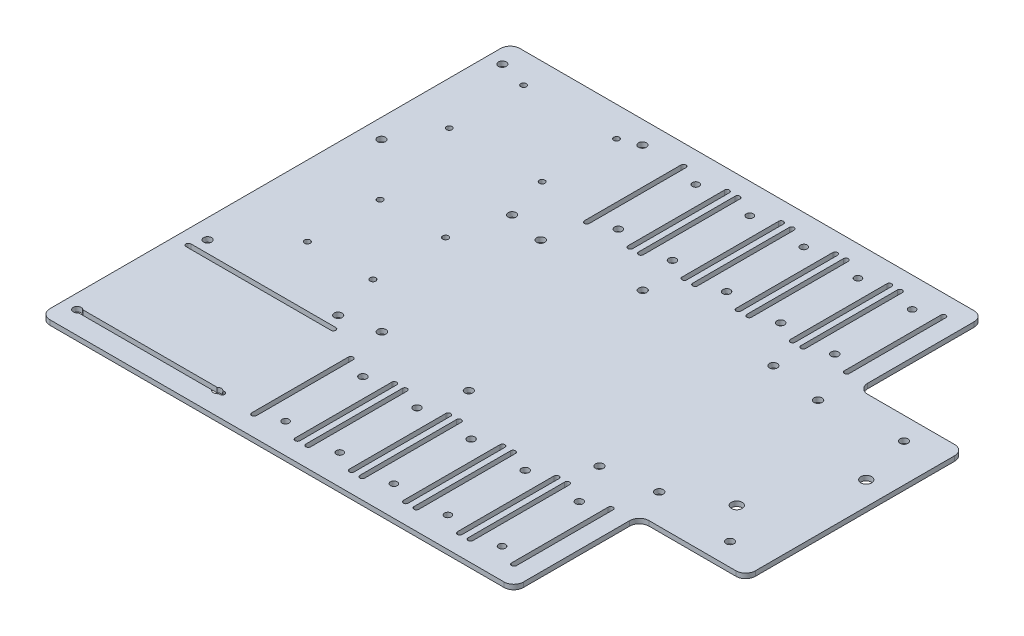
from build123d import *

# Parameters (mm, degrees)
SKETCH1_W           = 522.213812682
SKETCH1_H           = 731.32295859
BOSS_EXTRUDE1_DEPTH = 3.175
SKETCH3_W           = 1.5875
SKETCH3_H           = 63.5
CUT_EXTRUDE2_DEPTH  = 4.175
SKETCH5_R           = 2.44336951
SKETCH5_R_2         = 2.2479
CUT_EXTRUDE3_DEPTH  = 4.175
CUT_EXTRUDE6_DEPTH  = 4.175
CUT_EXTRUDE7_DEPTH  = 4.175
SKETCH10_W          = 95.25
SKETCH10_H          = 1.5875
CUT_EXTRUDE9_DEPTH  = 4.175
SKETCH11_W          = 522.213812682
SKETCH11_H          = 186.464479295
CUT_EXTRUDE10_DEPTH = 4.175
SKETCH12_W          = 244.054011645
SKETCH12_H          = 358.394
BOSS_EXTRUDE3_DEPTH = 3.175
SKETCH14_W          = 61.487666114
SKETCH14_H          = 358.394
SKETCH14_W_2        = 155.120959935
CUT_EXTRUDE12_DEPTH = 4.175
SKETCH15_W          = 381
SKETCH15_H          = 24.776559824
SKETCH15_W_2        = 31.995256138
SKETCH15_H_2        = 154.420440176
CUT_EXTRUDE13_DEPTH = 4.175
SKETCH16_R          = 2.6
CUT_EXTRUDE14_DEPTH = 4.175
CUT_EXTRUDE15_DEPTH = 4.175
SKETCH18_W          = 69.85
SKETCH18_H          = 82.55
CUT_EXTRUDE16_DEPTH = 4.175
FILLET2_R           = 6.35


with BuildPart() as part:
    # Sketch1 → Boss-Extrude1 (new body)
    with BuildSketch(Plane(origin=(0, 0, 0), x_dir=(1, 0, 0), z_dir=(0, 1, 0))):
        Rectangle(SKETCH1_W, SKETCH1_H)
    extrude(amount=BOSS_EXTRUDE1_DEPTH)

    # Sketch3 → Cut-Extrude2 (cut, through all)
    with BuildSketch(Plane(origin=(0, 3.175, 0), x_dir=(1, 0, 0), z_dir=(0, 1, 0))):
        with BuildLine():
            Line((-84.61375, -141.097), (-86.20125, -141.097))
            Line((-86.20125, -141.097), (-86.20125, -77.597))
            Line((-86.20125, -77.597), (-84.61375, -77.597))
            ThreePointArc((-84.61375, -77.597), (-86.20125, -76.0095), (-87.78875, -77.597))
            Line((-87.78875, -77.597), (-87.78875, -141.097))
            ThreePointArc((-87.78875, -141.097), (-86.20125, -142.6845), (-84.61375, -141.097))
        make_face()
        with Locations((-85.4075, -109.347)):
            Rectangle(SKETCH3_W, SKETCH3_H)
        with Locations((-58.42, -109.347)):
            Rectangle(SKETCH3_W, SKETCH3_H)
        with BuildLine():
            Line((-57.62625, -141.097), (-59.21375, -141.097))
            ThreePointArc((-59.21375, -141.097), (-57.62625, -142.6845), (-56.03875, -141.097))
            Line((-56.03875, -141.097), (-56.03875, -77.597))
            ThreePointArc((-56.03875, -77.597), (-57.62625, -76.0095), (-59.21375, -77.597))
            Line((-59.21375, -77.597), (-57.62625, -77.597))
            Line((-57.62625, -77.597), (-57.62625, -141.097))
        make_face()
        with BuildLine():
            Line((-49.05375, -141.097), (-49.05375, -77.597))
            ThreePointArc((-49.05375, -77.597), (-50.64125, -76.0095), (-52.22875, -77.597))
            Line((-52.22875, -77.597), (-52.22875, -141.097))
            ThreePointArc((-52.22875, -141.097), (-50.64125, -142.6845), (-49.05375, -141.097))
        make_face()
        with BuildLine():
            Line((-20.47875, -141.097), (-20.47875, -77.597))
            ThreePointArc((-20.47875, -77.597), (-22.06625, -76.0095), (-23.65375, -77.597))
            Line((-23.65375, -77.597), (-23.65375, -141.097))
            ThreePointArc((-23.65375, -141.097), (-22.06625, -142.6845), (-20.47875, -141.097))
        make_face()
        with BuildLine():
            Line((-13.49375, -141.097), (-13.49375, -77.597))
            ThreePointArc((-13.49375, -77.597), (-15.08125, -76.0095), (-16.66875, -77.597))
            Line((-16.66875, -77.597), (-16.66875, -141.097))
            ThreePointArc((-16.66875, -141.097), (-15.08125, -142.6845), (-13.49375, -141.097))
        make_face()
        with BuildLine():
            Line((15.08125, -141.097), (15.08125, -77.597))
            ThreePointArc((15.08125, -77.597), (13.49375, -76.0095), (11.90625, -77.597))
            Line((11.90625, -77.597), (11.90625, -141.097))
            ThreePointArc((11.90625, -141.097), (13.49375, -142.6845), (15.08125, -141.097))
        make_face()
        with BuildLine():
            Line((22.06625, -141.097), (22.06625, -77.597))
            ThreePointArc((22.06625, -77.597), (20.47875, -76.0095), (18.89125, -77.597))
            Line((18.89125, -77.597), (18.89125, -141.097))
            ThreePointArc((18.89125, -141.097), (20.47875, -142.6845), (22.06625, -141.097))
        make_face()
        with BuildLine():
            Line((50.64125, -141.097), (50.64125, -77.597))
            ThreePointArc((50.64125, -77.597), (49.05375, -76.0095), (47.46625, -77.597))
            Line((47.46625, -77.597), (47.46625, -141.097))
            ThreePointArc((47.46625, -141.097), (49.05375, -142.6845), (50.64125, -141.097))
        make_face()
        with BuildLine():
            Line((57.62625, -141.097), (57.62625, -77.597))
            ThreePointArc((57.62625, -77.597), (56.03875, -76.0095), (54.45125, -77.597))
            Line((54.45125, -77.597), (54.45125, -141.097))
            ThreePointArc((54.45125, -141.097), (56.03875, -142.6845), (57.62625, -141.097))
        make_face()
        with BuildLine():
            Line((86.20125, -141.097), (86.20125, -77.597))
            ThreePointArc((86.20125, -77.597), (84.61375, -76.0095), (83.02625, -77.597))
            Line((83.02625, -77.597), (83.02625, -141.097))
            ThreePointArc((83.02625, -141.097), (84.61375, -142.6845), (86.20125, -141.097))
        make_face()
        with BuildLine():
            ThreePointArc((-88.4682, -52.197), (-89.249346215, -50.311146215), (-91.1352, -49.53))
            Line((-91.1352, -49.53), (-91.1352, -52.197))
            Line((-91.1352, -52.197), (-88.4682, -52.197))
        make_face()
        with BuildLine():
            Line((-91.1352, -52.197), (-91.1352, -49.53))
            ThreePointArc((-91.1352, -49.53), (-93.021053785, -54.082853785), (-88.4682, -52.197))
            Line((-88.4682, -52.197), (-91.1352, -52.197))
        make_face()
        with BuildLine():
            ThreePointArc((-88.4682, -52.197), (-89.249346215, -50.311146215), (-91.1352, -49.53))
            Line((-91.1352, -49.53), (-91.1352, -52.197))
            Line((-91.1352, -52.197), (-88.4682, -52.197))
        make_face()
        with BuildLine():
            Line((-91.1352, -52.197), (-91.1352, -49.53))
            ThreePointArc((-91.1352, -49.53), (-93.021053785, -54.082853785), (-88.4682, -52.197))
            Line((-88.4682, -52.197), (-91.1352, -52.197))
        make_face()
        with BuildLine():
            ThreePointArc((-91.1352, 49.53), (-89.249346215, 50.311146215), (-88.4682, 52.197))
            Line((-88.4682, 52.197), (-91.1352, 52.197))
            Line((-91.1352, 52.197), (-91.1352, 49.53))
        make_face()
        with BuildLine():
            Line((-91.1352, 52.197), (-88.4682, 52.197))
            ThreePointArc((-88.4682, 52.197), (-93.021053785, 54.082853785), (-91.1352, 49.53))
            Line((-91.1352, 49.53), (-91.1352, 52.197))
        make_face()
        with BuildLine():
            ThreePointArc((-91.1352, 49.53), (-89.249346215, 50.311146215), (-88.4682, 52.197))
            Line((-88.4682, 52.197), (-91.1352, 52.197))
            Line((-91.1352, 52.197), (-91.1352, 49.53))
        make_face()
        with BuildLine():
            Line((-91.1352, 52.197), (-88.4682, 52.197))
            ThreePointArc((-88.4682, 52.197), (-93.021053785, 54.082853785), (-91.1352, 49.53))
            Line((-91.1352, 49.53), (-91.1352, 52.197))
        make_face()
        with BuildLine():
            ThreePointArc((93.8022, 52.197), (91.1352, 54.864), (88.4682, 52.197))
            Line((88.4682, 52.197), (91.1352, 52.197))
            Line((91.1352, 52.197), (91.1352, 49.53))
            ThreePointArc((91.1352, 49.53), (93.021053785, 50.311146215), (93.8022, 52.197))
        make_face()
        with BuildLine():
            Line((91.1352, 52.197), (88.4682, 52.197))
            ThreePointArc((88.4682, 52.197), (89.249346215, 50.311146215), (91.1352, 49.53))
            Line((91.1352, 49.53), (91.1352, 52.197))
        make_face()
        with BuildLine():
            ThreePointArc((93.8022, 52.197), (91.1352, 54.864), (88.4682, 52.197))
            Line((88.4682, 52.197), (91.1352, 52.197))
            Line((91.1352, 52.197), (91.1352, 49.53))
            ThreePointArc((91.1352, 49.53), (93.021053785, 50.311146215), (93.8022, 52.197))
        make_face()
        with BuildLine():
            Line((91.1352, 52.197), (88.4682, 52.197))
            ThreePointArc((88.4682, 52.197), (89.249346215, 50.311146215), (91.1352, 49.53))
            Line((91.1352, 49.53), (91.1352, 52.197))
        make_face()
        with BuildLine():
            ThreePointArc((93.8022, -52.197), (93.021053785, -50.311146215), (91.1352, -49.53))
            Line((91.1352, -49.53), (91.1352, -52.197))
            Line((91.1352, -52.197), (88.4682, -52.197))
            ThreePointArc((88.4682, -52.197), (91.1352, -54.864), (93.8022, -52.197))
        make_face()
        with BuildLine():
            Line((91.1352, -52.197), (91.1352, -49.53))
            ThreePointArc((91.1352, -49.53), (89.249346215, -50.311146215), (88.4682, -52.197))
            Line((88.4682, -52.197), (91.1352, -52.197))
        make_face()
        with BuildLine():
            ThreePointArc((93.8022, -52.197), (93.021053785, -50.311146215), (91.1352, -49.53))
            Line((91.1352, -49.53), (91.1352, -52.197))
            Line((91.1352, -52.197), (88.4682, -52.197))
            ThreePointArc((88.4682, -52.197), (91.1352, -54.864), (93.8022, -52.197))
        make_face()
        with BuildLine():
            Line((91.1352, -52.197), (91.1352, -49.53))
            ThreePointArc((91.1352, -49.53), (89.249346215, -50.311146215), (88.4682, -52.197))
            Line((88.4682, -52.197), (91.1352, -52.197))
        make_face()
        with BuildLine():
            ThreePointArc((86.20125, 77.597), (84.61375, 76.0095), (83.02625, 77.597))
            Line((83.02625, 77.597), (83.02625, 141.097))
            ThreePointArc((83.02625, 141.097), (84.61375, 142.6845), (86.20125, 141.097))
            Line((86.20125, 141.097), (86.20125, 77.597))
        make_face()
        with BuildLine():
            ThreePointArc((50.64125, 77.597), (49.05375, 76.0095), (47.46625, 77.597))
            Line((47.46625, 77.597), (47.46625, 141.097))
            ThreePointArc((47.46625, 141.097), (49.05375, 142.6845), (50.64125, 141.097))
            Line((50.64125, 141.097), (50.64125, 77.597))
        make_face()
        with BuildLine():
            ThreePointArc((57.62625, 77.597), (56.03875, 76.0095), (54.45125, 77.597))
            Line((54.45125, 77.597), (54.45125, 141.097))
            ThreePointArc((54.45125, 141.097), (56.03875, 142.6845), (57.62625, 141.097))
            Line((57.62625, 141.097), (57.62625, 77.597))
        make_face()
        with BuildLine():
            ThreePointArc((15.08125, 77.597), (13.49375, 76.0095), (11.90625, 77.597))
            Line((11.90625, 77.597), (11.90625, 141.097))
            ThreePointArc((11.90625, 141.097), (13.49375, 142.6845), (15.08125, 141.097))
            Line((15.08125, 141.097), (15.08125, 77.597))
        make_face()
        with BuildLine():
            ThreePointArc((22.06625, 77.597), (20.47875, 76.0095), (18.89125, 77.597))
            Line((18.89125, 77.597), (18.89125, 141.097))
            ThreePointArc((18.89125, 141.097), (20.47875, 142.6845), (22.06625, 141.097))
            Line((22.06625, 141.097), (22.06625, 77.597))
        make_face()
        with BuildLine():
            ThreePointArc((-20.47875, 77.597), (-22.06625, 76.0095), (-23.65375, 77.597))
            Line((-23.65375, 77.597), (-23.65375, 141.097))
            ThreePointArc((-23.65375, 141.097), (-22.06625, 142.6845), (-20.47875, 141.097))
            Line((-20.47875, 141.097), (-20.47875, 77.597))
        make_face()
        with BuildLine():
            ThreePointArc((-13.49375, 77.597), (-15.08125, 76.0095), (-16.66875, 77.597))
            Line((-16.66875, 77.597), (-16.66875, 141.097))
            ThreePointArc((-16.66875, 141.097), (-15.08125, 142.6845), (-13.49375, 141.097))
            Line((-13.49375, 141.097), (-13.49375, 77.597))
        make_face()
        with BuildLine():
            ThreePointArc((-56.03875, 77.597), (-57.62625, 76.0095), (-59.21375, 77.597))
            Line((-59.21375, 77.597), (-59.21375, 141.097))
            ThreePointArc((-59.21375, 141.097), (-57.62625, 142.6845), (-56.03875, 141.097))
            Line((-56.03875, 141.097), (-56.03875, 77.597))
        make_face()
        with BuildLine():
            ThreePointArc((-49.05375, 77.597), (-50.64125, 76.0095), (-52.22875, 77.597))
            Line((-52.22875, 77.597), (-52.22875, 141.097))
            ThreePointArc((-52.22875, 141.097), (-50.64125, 142.6845), (-49.05375, 141.097))
            Line((-49.05375, 141.097), (-49.05375, 77.597))
        make_face()
        with BuildLine():
            ThreePointArc((-84.61375, 77.597), (-86.20125, 76.0095), (-87.78875, 77.597))
            Line((-87.78875, 77.597), (-87.78875, 141.097))
            ThreePointArc((-87.78875, 141.097), (-86.20125, 142.6845), (-84.61375, 141.097))
            Line((-84.61375, 141.097), (-84.61375, 77.597))
        make_face()
    extrude(amount=-CUT_EXTRUDE2_DEPTH, mode=Mode.SUBTRACT)

    # Sketch5 → Cut-Extrude3 (cut, through all)
    with BuildSketch(Plane(origin=(0, 3.175, 0), x_dir=(1, 0, 0), z_dir=(0, 1, 0))):
        with Locations((-71.8467829, -83.947)):
            Circle(SKETCH5_R)
        with Locations((-71.8467829, -134.747)):
            Circle(SKETCH5_R_2)
        with Locations((-36.2867829, -134.747)):
            Circle(SKETCH5_R_2)
        with Locations((-36.2867829, -83.947)):
            Circle(SKETCH5_R)
        with Locations((70.3932171, -83.947)):
            Circle(SKETCH5_R)
        with Locations((70.3932171, -134.747)):
            Circle(SKETCH5_R_2)
        with Locations((34.8332171, -83.947)):
            Circle(SKETCH5_R)
        with Locations((34.8332171, -134.747)):
            Circle(SKETCH5_R_2)
        with Locations((-0.7267829, -134.747)):
            Circle(SKETCH5_R_2)
        with Locations((-0.7267829, -83.947)):
            Circle(SKETCH5_R)
        with Locations((70.3932171, 83.947)):
            Circle(SKETCH5_R)
        with Locations((34.8332171, 83.947)):
            Circle(SKETCH5_R)
        with Locations((34.8332171, 134.747)):
            Circle(SKETCH5_R_2)
        with Locations((70.3932171, 134.747)):
            Circle(SKETCH5_R_2)
        with Locations((-0.7267829, 134.747)):
            Circle(SKETCH5_R_2)
        with Locations((-0.7267829, 83.947)):
            Circle(SKETCH5_R)
        with Locations((-36.2867829, 83.947)):
            Circle(SKETCH5_R)
        with Locations((-36.2867829, 134.747)):
            Circle(SKETCH5_R_2)
        with Locations((-71.8467829, 134.747)):
            Circle(SKETCH5_R_2)
        with Locations((-71.8467829, 83.947)):
            Circle(SKETCH5_R)
    extrude(amount=-CUT_EXTRUDE3_DEPTH, mode=Mode.SUBTRACT)

    # Sketch8 → Cut-Extrude6 (cut, through all)
    with BuildSketch(Plane(origin=(0, 3.175, 0), x_dir=(1, 0, 0), z_dir=(0, 1, 0))):
        with BuildLine():
            ThreePointArc((148.68525, 22.761479295), (149.726778286, 20.247007581), (152.24125, 19.205479295))
            Line((152.24125, 19.205479295), (152.24125, 22.761479295))
            Line((152.24125, 22.761479295), (148.68525, 22.761479295))
        make_face()
        with BuildLine():
            Line((152.24125, 22.761479295), (152.24125, 19.205479295))
            ThreePointArc((152.24125, 19.205479295), (154.755721714, 20.247007581), (155.79725, 22.761479295))
            ThreePointArc((155.79725, 22.761479295), (152.24125, 26.317479295), (148.68525, 22.761479295))
            Line((148.68525, 22.761479295), (152.24125, 22.761479295))
        make_face()
        with BuildLine():
            ThreePointArc((148.68525, 22.761479295), (149.726778286, 20.247007581), (152.24125, 19.205479295))
            Line((152.24125, 19.205479295), (152.24125, 22.761479295))
            Line((152.24125, 22.761479295), (148.68525, 22.761479295))
        make_face()
        with BuildLine():
            Line((152.24125, 22.761479295), (152.24125, 19.205479295))
            ThreePointArc((152.24125, 19.205479295), (154.755721714, 20.247007581), (155.79725, 22.761479295))
            ThreePointArc((155.79725, 22.761479295), (152.24125, 26.317479295), (148.68525, 22.761479295))
            Line((148.68525, 22.761479295), (152.24125, 22.761479295))
        make_face()
        with BuildLine():
            ThreePointArc((124.30125, -30.832520705), (121.786778286, -36.902992419), (127.85725, -34.388520705))
            Line((127.85725, -34.388520705), (124.30125, -34.388520705))
            Line((124.30125, -34.388520705), (124.30125, -30.832520705))
        make_face()
        with BuildLine():
            Line((124.30125, -34.388520705), (127.85725, -34.388520705))
            ThreePointArc((127.85725, -34.388520705), (126.815721714, -31.874048991), (124.30125, -30.832520705))
            Line((124.30125, -30.832520705), (124.30125, -34.388520705))
        make_face()
        with BuildLine():
            ThreePointArc((124.30125, -30.832520705), (121.786778286, -36.902992419), (127.85725, -34.388520705))
            Line((127.85725, -34.388520705), (124.30125, -34.388520705))
            Line((124.30125, -34.388520705), (124.30125, -30.832520705))
        make_face()
        with BuildLine():
            Line((124.30125, -34.388520705), (127.85725, -34.388520705))
            ThreePointArc((127.85725, -34.388520705), (126.815721714, -31.874048991), (124.30125, -30.832520705))
            Line((124.30125, -30.832520705), (124.30125, -34.388520705))
        make_face()
    extrude(amount=-CUT_EXTRUDE6_DEPTH, mode=Mode.SUBTRACT)

    # Sketch9 → Cut-Extrude7 (cut, through all)
    with BuildSketch(Plane(origin=(0, 3.175, 0), x_dir=(1, 0, 0), z_dir=(0, 1, 0))):
        with BuildLine():
            Line((-166.923706341, -23.4442), (-166.923706341, -25.3492))
            Line((-166.923706341, -25.3492), (-165.018706341, -25.3492))
            ThreePointArc((-165.018706341, -25.3492), (-165.576667923, -24.002161582), (-166.923706341, -23.4442))
        make_face()
        with BuildLine():
            Line((-165.018706341, -25.3492), (-166.923706341, -25.3492))
            Line((-166.923706341, -25.3492), (-166.923706341, -23.4442))
            ThreePointArc((-166.923706341, -23.4442), (-168.270744759, -26.696238418), (-165.018706341, -25.3492))
        make_face()
        with BuildLine():
            Line((-166.923706341, -23.4442), (-166.923706341, -25.3492))
            Line((-166.923706341, -25.3492), (-165.018706341, -25.3492))
            ThreePointArc((-165.018706341, -25.3492), (-165.576667923, -24.002161582), (-166.923706341, -23.4442))
        make_face()
        with BuildLine():
            Line((-165.018706341, -25.3492), (-166.923706341, -25.3492))
            Line((-166.923706341, -25.3492), (-166.923706341, -23.4442))
            ThreePointArc((-166.923706341, -23.4442), (-168.270744759, -26.696238418), (-165.018706341, -25.3492))
        make_face()
        with BuildLine():
            ThreePointArc((-165.018706341, 22.4028), (-168.270744759, 23.749838418), (-166.923706341, 20.4978))
            Line((-166.923706341, 20.4978), (-166.923706341, 22.4028))
            Line((-166.923706341, 22.4028), (-165.018706341, 22.4028))
        make_face()
        with BuildLine():
            Line((-166.923706341, 22.4028), (-166.923706341, 20.4978))
            ThreePointArc((-166.923706341, 20.4978), (-165.576667923, 21.055761582), (-165.018706341, 22.4028))
            Line((-165.018706341, 22.4028), (-166.923706341, 22.4028))
        make_face()
        with BuildLine():
            ThreePointArc((-165.018706341, 22.4028), (-168.270744759, 23.749838418), (-166.923706341, 20.4978))
            Line((-166.923706341, 20.4978), (-166.923706341, 22.4028))
            Line((-166.923706341, 22.4028), (-165.018706341, 22.4028))
        make_face()
        with BuildLine():
            Line((-166.923706341, 22.4028), (-166.923706341, 20.4978))
            ThreePointArc((-166.923706341, 20.4978), (-165.576667923, 21.055761582), (-165.018706341, 22.4028))
            Line((-165.018706341, 22.4028), (-166.923706341, 22.4028))
        make_face()
        with BuildLine():
            ThreePointArc((-125.775706341, 22.4028), (-125.217744759, 21.055761582), (-123.870706341, 20.4978))
            Line((-123.870706341, 20.4978), (-123.870706341, 22.4028))
            Line((-123.870706341, 22.4028), (-125.775706341, 22.4028))
        make_face()
        with BuildLine():
            Line((-123.870706341, 22.4028), (-123.870706341, 20.4978))
            ThreePointArc((-123.870706341, 20.4978), (-122.523667923, 21.055761582), (-121.965706341, 22.4028))
            ThreePointArc((-121.965706341, 22.4028), (-123.870706341, 24.3078), (-125.775706341, 22.4028))
            Line((-125.775706341, 22.4028), (-123.870706341, 22.4028))
        make_face()
        with BuildLine():
            ThreePointArc((-125.775706341, 22.4028), (-125.217744759, 21.055761582), (-123.870706341, 20.4978))
            Line((-123.870706341, 20.4978), (-123.870706341, 22.4028))
            Line((-123.870706341, 22.4028), (-125.775706341, 22.4028))
        make_face()
        with BuildLine():
            Line((-123.870706341, 22.4028), (-123.870706341, 20.4978))
            ThreePointArc((-123.870706341, 20.4978), (-122.523667923, 21.055761582), (-121.965706341, 22.4028))
            ThreePointArc((-121.965706341, 22.4028), (-123.870706341, 24.3078), (-125.775706341, 22.4028))
            Line((-125.775706341, 22.4028), (-123.870706341, 22.4028))
        make_face()
        with BuildLine():
            ThreePointArc((-123.870706341, -23.4442), (-125.217744759, -24.002161582), (-125.775706341, -25.3492))
            Line((-125.775706341, -25.3492), (-123.870706341, -25.3492))
            Line((-123.870706341, -25.3492), (-123.870706341, -23.4442))
        make_face()
        with BuildLine():
            Line((-123.870706341, -25.3492), (-125.775706341, -25.3492))
            ThreePointArc((-125.775706341, -25.3492), (-123.870706341, -27.2542), (-121.965706341, -25.3492))
            ThreePointArc((-121.965706341, -25.3492), (-122.523667923, -24.002161582), (-123.870706341, -23.4442))
            Line((-123.870706341, -23.4442), (-123.870706341, -25.3492))
        make_face()
        with BuildLine():
            ThreePointArc((-123.870706341, -23.4442), (-125.217744759, -24.002161582), (-125.775706341, -25.3492))
            Line((-125.775706341, -25.3492), (-123.870706341, -25.3492))
            Line((-123.870706341, -25.3492), (-123.870706341, -23.4442))
        make_face()
        with BuildLine():
            Line((-123.870706341, -25.3492), (-125.775706341, -25.3492))
            ThreePointArc((-125.775706341, -25.3492), (-123.870706341, -27.2542), (-121.965706341, -25.3492))
            ThreePointArc((-121.965706341, -25.3492), (-122.523667923, -24.002161582), (-123.870706341, -23.4442))
            Line((-123.870706341, -23.4442), (-123.870706341, -25.3492))
        make_face()
        with BuildLine():
            ThreePointArc((-123.870706341, 87.74176), (-125.171047428, 87.203141086), (-125.709666341, 85.9028))
            Line((-125.709666341, 85.9028), (-123.870706341, 85.9028))
            Line((-123.870706341, 85.9028), (-123.870706341, 87.74176))
        make_face()
        with BuildLine():
            Line((-123.870706341, 85.9028), (-125.709666341, 85.9028))
            ThreePointArc((-125.709666341, 85.9028), (-123.870706341, 84.06384), (-122.031746341, 85.9028))
            ThreePointArc((-122.031746341, 85.9028), (-122.570365255, 87.203141086), (-123.870706341, 87.74176))
            Line((-123.870706341, 87.74176), (-123.870706341, 85.9028))
        make_face()
        with BuildLine():
            ThreePointArc((-123.870706341, 87.74176), (-125.171047428, 87.203141086), (-125.709666341, 85.9028))
            Line((-125.709666341, 85.9028), (-123.870706341, 85.9028))
            Line((-123.870706341, 85.9028), (-123.870706341, 87.74176))
        make_face()
        with BuildLine():
            Line((-123.870706341, 85.9028), (-125.709666341, 85.9028))
            ThreePointArc((-125.709666341, 85.9028), (-123.870706341, 84.06384), (-122.031746341, 85.9028))
            ThreePointArc((-122.031746341, 85.9028), (-122.570365255, 87.203141086), (-123.870706341, 87.74176))
            Line((-123.870706341, 87.74176), (-123.870706341, 85.9028))
        make_face()
        with BuildLine():
            ThreePointArc((-125.709666341, 134.747), (-125.171047428, 133.446658914), (-123.870706341, 132.90804))
            Line((-123.870706341, 132.90804), (-123.870706341, 134.747))
            Line((-123.870706341, 134.747), (-125.709666341, 134.747))
        make_face()
        with BuildLine():
            Line((-123.870706341, 134.747), (-123.870706341, 132.90804))
            ThreePointArc((-123.870706341, 132.90804), (-122.570365255, 133.446658914), (-122.031746341, 134.747))
            ThreePointArc((-122.031746341, 134.747), (-123.870706341, 136.58596), (-125.709666341, 134.747))
            Line((-125.709666341, 134.747), (-123.870706341, 134.747))
        make_face()
        with BuildLine():
            ThreePointArc((-125.709666341, 134.747), (-125.171047428, 133.446658914), (-123.870706341, 132.90804))
            Line((-123.870706341, 132.90804), (-123.870706341, 134.747))
            Line((-123.870706341, 134.747), (-125.709666341, 134.747))
        make_face()
        with BuildLine():
            Line((-123.870706341, 134.747), (-123.870706341, 132.90804))
            ThreePointArc((-123.870706341, 132.90804), (-122.570365255, 133.446658914), (-122.031746341, 134.747))
            ThreePointArc((-122.031746341, 134.747), (-123.870706341, 136.58596), (-125.709666341, 134.747))
            Line((-125.709666341, 134.747), (-123.870706341, 134.747))
        make_face()
        with BuildLine():
            ThreePointArc((-183.067946341, 134.747), (-186.207247428, 136.047341086), (-184.906906341, 132.90804))
            Line((-184.906906341, 132.90804), (-184.906906341, 134.747))
            Line((-184.906906341, 134.747), (-183.067946341, 134.747))
        make_face()
        with BuildLine():
            Line((-184.906906341, 134.747), (-184.906906341, 132.90804))
            ThreePointArc((-184.906906341, 132.90804), (-183.606565255, 133.446658914), (-183.067946341, 134.747))
            Line((-183.067946341, 134.747), (-184.906906341, 134.747))
        make_face()
        with BuildLine():
            ThreePointArc((-183.067946341, 134.747), (-186.207247428, 136.047341086), (-184.906906341, 132.90804))
            Line((-184.906906341, 132.90804), (-184.906906341, 134.747))
            Line((-184.906906341, 134.747), (-183.067946341, 134.747))
        make_face()
        with BuildLine():
            Line((-184.906906341, 134.747), (-184.906906341, 132.90804))
            ThreePointArc((-184.906906341, 132.90804), (-183.606565255, 133.446658914), (-183.067946341, 134.747))
            Line((-183.067946341, 134.747), (-184.906906341, 134.747))
        make_face()
        with BuildLine():
            Line((-184.906906341, 87.74176), (-184.906906341, 85.9028))
            Line((-184.906906341, 85.9028), (-183.067946341, 85.9028))
            ThreePointArc((-183.067946341, 85.9028), (-183.606565255, 87.203141086), (-184.906906341, 87.74176))
        make_face()
        with BuildLine():
            Line((-183.067946341, 85.9028), (-184.906906341, 85.9028))
            Line((-184.906906341, 85.9028), (-184.906906341, 87.74176))
            ThreePointArc((-184.906906341, 87.74176), (-186.207247428, 84.602458914), (-183.067946341, 85.9028))
        make_face()
        with BuildLine():
            Line((-184.906906341, 87.74176), (-184.906906341, 85.9028))
            Line((-184.906906341, 85.9028), (-183.067946341, 85.9028))
            ThreePointArc((-183.067946341, 85.9028), (-183.606565255, 87.203141086), (-184.906906341, 87.74176))
        make_face()
        with BuildLine():
            Line((-183.067946341, 85.9028), (-184.906906341, 85.9028))
            Line((-184.906906341, 85.9028), (-184.906906341, 87.74176))
            ThreePointArc((-184.906906341, 87.74176), (-186.207247428, 84.602458914), (-183.067946341, 85.9028))
        make_face()
    extrude(amount=-CUT_EXTRUDE7_DEPTH, mode=Mode.SUBTRACT)

    # Sketch10 → Cut-Extrude9 (cut, through all)
    with BuildSketch(Plane(origin=(0, 3.175, 0), x_dir=(1, 0, 0), z_dir=(0, 1, 0))):
        with BuildLine():
            Line((-108.706906341, -139.5095), (-203.956906341, -139.5095))
            Line((-203.956906341, -139.5095), (-203.956906341, -137.922))
            ThreePointArc((-203.956906341, -137.922), (-205.544406341, -139.5095), (-203.956906341, -141.097))
            Line((-203.956906341, -141.097), (-108.706906341, -141.097))
            ThreePointArc((-108.706906341, -141.097), (-107.119406341, -139.5095), (-108.706906341, -137.922))
            Line((-108.706906341, -137.922), (-108.706906341, -139.5095))
        make_face()
        with Locations((-156.331906341, -138.71575)):
            Rectangle(SKETCH10_W, SKETCH10_H)
        with Locations((-156.331906341, -67.27825)):
            Rectangle(SKETCH10_W, SKETCH10_H)
        with BuildLine():
            ThreePointArc((-203.956906341, -64.897), (-205.544406341, -66.4845), (-203.956906341, -68.072))
            Line((-203.956906341, -68.072), (-203.956906341, -66.4845))
            Line((-203.956906341, -66.4845), (-108.706906341, -66.4845))
            Line((-108.706906341, -66.4845), (-108.706906341, -68.072))
            ThreePointArc((-108.706906341, -68.072), (-107.119406341, -66.4845), (-108.706906341, -64.897))
            Line((-108.706906341, -64.897), (-203.956906341, -64.897))
        make_face()
    extrude(amount=-CUT_EXTRUDE9_DEPTH, mode=Mode.SUBTRACT)

    # Sketch11 → Cut-Extrude10 (cut, through all)
    with BuildSketch(Plane(origin=(0, 3.175, 0), x_dir=(1, 0, 0), z_dir=(0, 1, 0))):
        with Locations((0, -272.429239648)):
            Rectangle(SKETCH11_W, SKETCH11_H)
        with Locations((0, 272.429239648)):
            Rectangle(SKETCH11_W, SKETCH11_H)
    extrude(amount=-CUT_EXTRUDE10_DEPTH, mode=Mode.SUBTRACT)

    # Sketch12 → Boss-Extrude3 (add)
    with BuildSketch(Plane(origin=(0, 3.175, 0), x_dir=(1, 0, 0), z_dir=(0, 1, 0))):
        with Locations((-383.133912163, 0)):
            Rectangle(SKETCH12_W, SKETCH12_H)
    extrude(amount=-BOSS_EXTRUDE3_DEPTH)

    # Sketch14 → Cut-Extrude12 (cut, through all)
    with BuildSketch(Plane.XZ):
        with Locations((230.363073284, 0)):
            Rectangle(SKETCH14_W, SKETCH14_H)
        with Locations((-427.600438019, 0)):
            Rectangle(SKETCH14_W_2, SKETCH14_H)
    extrude(amount=-CUT_EXTRUDE12_DEPTH, mode=Mode.SUBTRACT)

    # Sketch15 → Cut-Extrude13 (cut, through all)
    with BuildSketch(Plane.XZ):
        Polygon((-350.039958051, 0), (-213.376015911, 0), (-213.376015911, 154.420440176), (-213.376015911, 179.197), (-350.039958051, 179.197), align=None)
        Polygon((-350.039958051, -179.197), (-213.376015911, -179.197), (-213.376015911, -154.420440176), (-213.376015911, 0), (-350.039958051, 0), align=None)
        with Locations((-22.876015911, 166.808720088)):
            Rectangle(SKETCH15_W, SKETCH15_H)
        with Locations((-22.876015911, -166.808720088)):
            Rectangle(SKETCH15_W, SKETCH15_H)
        with Locations((183.621612158, 166.808720088)):
            Rectangle(SKETCH15_W_2, SKETCH15_H)
        with Locations((183.621612158, 77.210220088)):
            Rectangle(SKETCH15_W_2, SKETCH15_H_2)
        with Locations((183.621612158, -77.210220088)):
            Rectangle(SKETCH15_W_2, SKETCH15_H_2)
        with Locations((183.621612158, -166.808720088)):
            Rectangle(SKETCH15_W_2, SKETCH15_H)
    extrude(amount=-CUT_EXTRUDE13_DEPTH, mode=Mode.SUBTRACT)

    # Sketch16 → Cut-Extrude14 (cut, through all)
    with BuildSketch(Plane.XZ):
        with Locations((142.672554812, -57.15)):
            Circle(SKETCH16_R)
        with Locations((142.672554812, 57.15)):
            Circle(SKETCH16_R)
        with Locations((56.820554812, 57.15)):
            Circle(SKETCH16_R)
        with Locations((56.820554812, -57.15)):
            Circle(SKETCH16_R)
        with Locations((-29.031445188, -57.15)):
            Circle(SKETCH16_R)
        with Locations((-29.031445188, 57.15)):
            Circle(SKETCH16_R)
        with Locations((-114.883445188, 57.15)):
            Circle(SKETCH16_R)
        with Locations((-200.735445188, -57.15)):
            Circle(SKETCH16_R)
        with Locations((-200.735445188, 57.15)):
            Circle(SKETCH16_R)
        with Locations((-114.883445188, -57.15)):
            Circle(SKETCH16_R)
    extrude(amount=-CUT_EXTRUDE14_DEPTH, mode=Mode.SUBTRACT)

    # Sketch17 → Cut-Extrude15 (cut, through all)
    with BuildSketch(Plane(origin=(0, 0, 0), x_dir=(-1, 0, 0), z_dir=(0, -1, 0))):
        with BuildLine():
            Line((203.846945188, 139.7), (203.846945188, 137.1))
            ThreePointArc((203.846945188, 137.1), (205.685422819, 137.861522369), (206.446945188, 139.7))
            ThreePointArc((206.446945188, 139.7), (205.685422819, 141.538477631), (203.846945188, 142.3))
            Line((203.846945188, 142.3), (203.846945188, 139.7))
        make_face()
        with BuildLine():
            ThreePointArc((201.246945188, 139.7), (202.008467557, 137.861522369), (203.846945188, 137.1))
            Line((203.846945188, 137.1), (203.846945188, 139.7))
            Line((203.846945188, 139.7), (201.246945188, 139.7))
        make_face()
        with BuildLine():
            Line((201.246945188, 139.7), (203.846945188, 139.7))
            Line((203.846945188, 139.7), (203.846945188, 142.3))
            ThreePointArc((203.846945188, 142.3), (202.008467557, 141.538477631), (201.246945188, 139.7))
        make_face()
        with BuildLine():
            ThreePointArc((111.771945188, 142.3), (109.171945188, 139.7), (111.771945188, 137.1))
            Line((111.771945188, 137.1), (111.771945188, 139.7))
            Line((111.771945188, 139.7), (111.771945188, 142.3))
        make_face()
        with BuildLine():
            Line((111.771945188, 139.7), (111.771945188, 137.1))
            ThreePointArc((111.771945188, 137.1), (113.610422819, 137.861522369), (114.371945188, 139.7))
            Line((114.371945188, 139.7), (111.771945188, 139.7))
        make_face()
        with BuildLine():
            Line((111.771945188, 142.3), (111.771945188, 139.7))
            Line((111.771945188, 139.7), (114.371945188, 139.7))
            ThreePointArc((114.371945188, 139.7), (113.610422819, 141.538477631), (111.771945188, 142.3))
        make_face()
        with BuildLine():
            ThreePointArc((111.771945188, -137.1), (109.933467557, -141.538477631), (114.371945188, -139.7))
            Line((114.371945188, -139.7), (111.771945188, -139.7))
            Line((111.771945188, -139.7), (111.771945188, -137.1))
        make_face()
        with BuildLine():
            Line((111.771945188, -139.7), (114.371945188, -139.7))
            ThreePointArc((114.371945188, -139.7), (113.610422819, -137.861522369), (111.771945188, -137.1))
            Line((111.771945188, -137.1), (111.771945188, -139.7))
        make_face()
        with BuildLine():
            ThreePointArc((111.771945188, -137.1), (109.933467557, -141.538477631), (114.371945188, -139.7))
            Line((114.371945188, -139.7), (111.771945188, -139.7))
            Line((111.771945188, -139.7), (111.771945188, -137.1))
        make_face()
        with BuildLine():
            Line((111.771945188, -139.7), (114.371945188, -139.7))
            ThreePointArc((114.371945188, -139.7), (113.610422819, -137.861522369), (111.771945188, -137.1))
            Line((111.771945188, -137.1), (111.771945188, -139.7))
        make_face()
        with BuildLine():
            Line((203.846945188, -137.1), (203.846945188, -139.7))
            Line((203.846945188, -139.7), (203.846945188, -142.3))
            ThreePointArc((203.846945188, -142.3), (205.685422819, -141.538477631), (206.446945188, -139.7))
            ThreePointArc((206.446945188, -139.7), (205.685422819, -137.861522369), (203.846945188, -137.1))
        make_face()
        with BuildLine():
            ThreePointArc((203.846945188, -137.1), (202.008467557, -137.861522369), (201.246945188, -139.7))
            Line((201.246945188, -139.7), (203.846945188, -139.7))
            Line((203.846945188, -139.7), (203.846945188, -137.1))
        make_face()
        with BuildLine():
            Line((203.846945188, -139.7), (201.246945188, -139.7))
            ThreePointArc((201.246945188, -139.7), (202.008467557, -141.538477631), (203.846945188, -142.3))
            Line((203.846945188, -142.3), (203.846945188, -139.7))
        make_face()
        with BuildLine():
            ThreePointArc((203.846945188, -137.1), (202.008467557, -137.861522369), (201.246945188, -139.7))
            Line((201.246945188, -139.7), (203.846945188, -139.7))
            Line((203.846945188, -139.7), (203.846945188, -137.1))
        make_face()
    extrude(amount=-CUT_EXTRUDE15_DEPTH, mode=Mode.SUBTRACT)

    # Sketch18 → Cut-Extrude16 (cut, through all)
    with BuildSketch(Plane.XZ):
        with Locations((132.698984089, -113.145440176)):
            Rectangle(SKETCH18_W, SKETCH18_H)
        with Locations((132.698984089, 113.145440176)):
            Rectangle(SKETCH18_W, SKETCH18_H)
    extrude(amount=-CUT_EXTRUDE16_DEPTH, mode=Mode.SUBTRACT)

    # Fillet2
    fillet2_edges = [part.edges().sort_by_distance(p)[0] for p in [
        (-213.376015911, 1.5875, 154.420440176),
        (-213.376015911, 1.5875, -154.420440176),
        (97.773984089, 1.5875, -154.420440176),
        (97.773984089, 1.5875, -71.870440176),
        (167.623984089, 1.5875, -71.870440176),
        (167.623984089, 1.5875, 71.870440176),
        (97.773984089, 1.5875, 71.870440176),
        (97.773984089, 1.5875, 154.420440176),
    ]]
    fillet(fillet2_edges, radius=FILLET2_R)


solid = part.part
